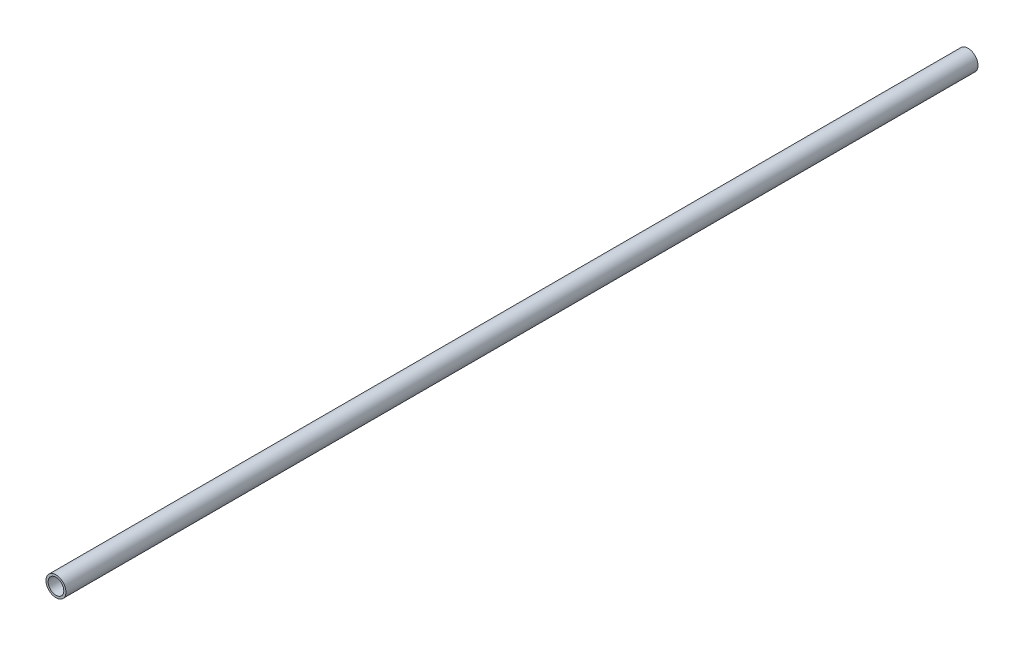
from build123d import *

# Parameters (mm, degrees)
SKETCH3_R                = 13.335
SKETCH3_R_2              = 10.4648
BOSS_EXTRUDE1_DEPTH      = 762
BOSS_EXTRUDE1_DEPTH_BACK = 762
SKETCH4_R                = 13.335
SKETCH4_R_2              = 10.4648
CUT_EXTRUDE2_DEPTH       = 304.181669


with BuildPart() as part:
    # Sketch3 → Boss-Extrude1 (new body, two sides)
    with BuildSketch(Plane.XY) as boss_extrude1_sk:
        Circle(SKETCH3_R)
        Circle(SKETCH3_R_2, mode=Mode.SUBTRACT)
    extrude(amount=BOSS_EXTRUDE1_DEPTH)
    extrude(boss_extrude1_sk.sketch, amount=-BOSS_EXTRUDE1_DEPTH_BACK)

    # Sketch4 → Cut-Extrude2 (cut)
    with BuildSketch(Plane.XY.offset(762)):
        Circle(SKETCH4_R)
        Circle(SKETCH4_R_2, mode=Mode.SUBTRACT)
    extrude(amount=-CUT_EXTRUDE2_DEPTH, mode=Mode.SUBTRACT)


solid = part.part
